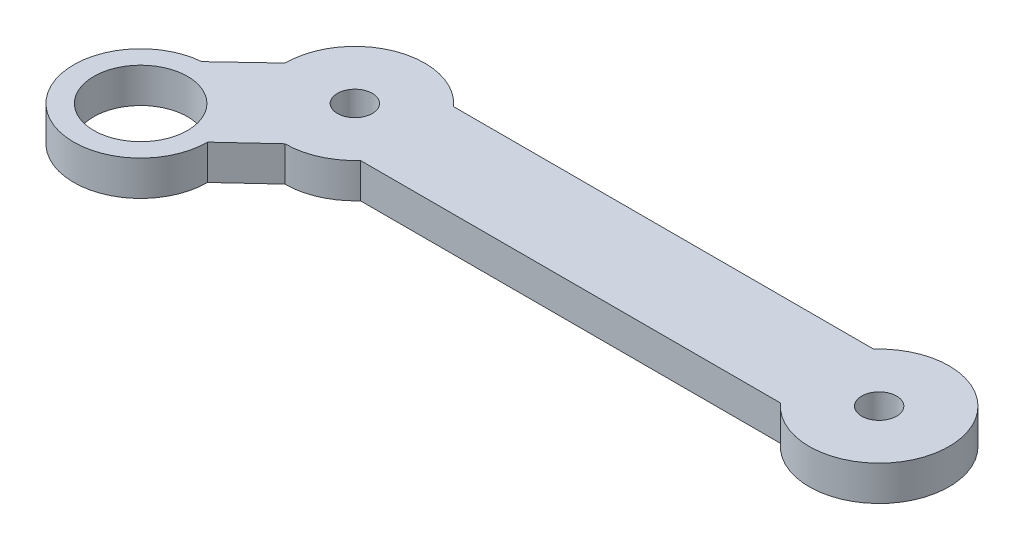
from build123d import *

# Parameters (mm, degrees)
ESQUISSE10_R       = 4.024
ESQUISSE10_R_2     = 1.5
BOSS_EXTRU_1_DEPTH = 3


with BuildPart() as part:
    # Esquisse10 → Boss.-Extru.1 (new body)
    with BuildSketch(Plane(origin=(0, 0, 0), x_dir=(1, 0, 0), z_dir=(0, 1, 0))):
        with BuildLine():
            Line((-4.472135955, 4), (-40.527864045, 4))
            ThreePointArc((-40.527864045, 4), (-47.140932539, 5.605034154), (-51, 0))
            Line((-51, 0), (-54.677584007, -3.462895596))
            ThreePointArc((-54.677584007, -3.462895596), (-58.082929496, -13.426321088), (-48.442388155, -9.192388155))
            Line((-48.442388155, -9.192388155), (-45, -6))
            ThreePointArc((-45, -6), (-42.550510257, -5.477225575), (-40.527864045, -4))
            Line((-40.527864045, -4), (-4.472135955, -4))
            ThreePointArc((-4.472135955, -4), (6, 0), (-4.472135955, 4))
        make_face()
        with Locations((-54.192388155, -9.192388155)):
            Circle(ESQUISSE10_R, mode=Mode.SUBTRACT)
        with Locations((-45, 0)):
            Circle(ESQUISSE10_R_2, mode=Mode.SUBTRACT)
        Circle(ESQUISSE10_R_2, mode=Mode.SUBTRACT)
    extrude(amount=BOSS_EXTRU_1_DEPTH)


solid = part.part
